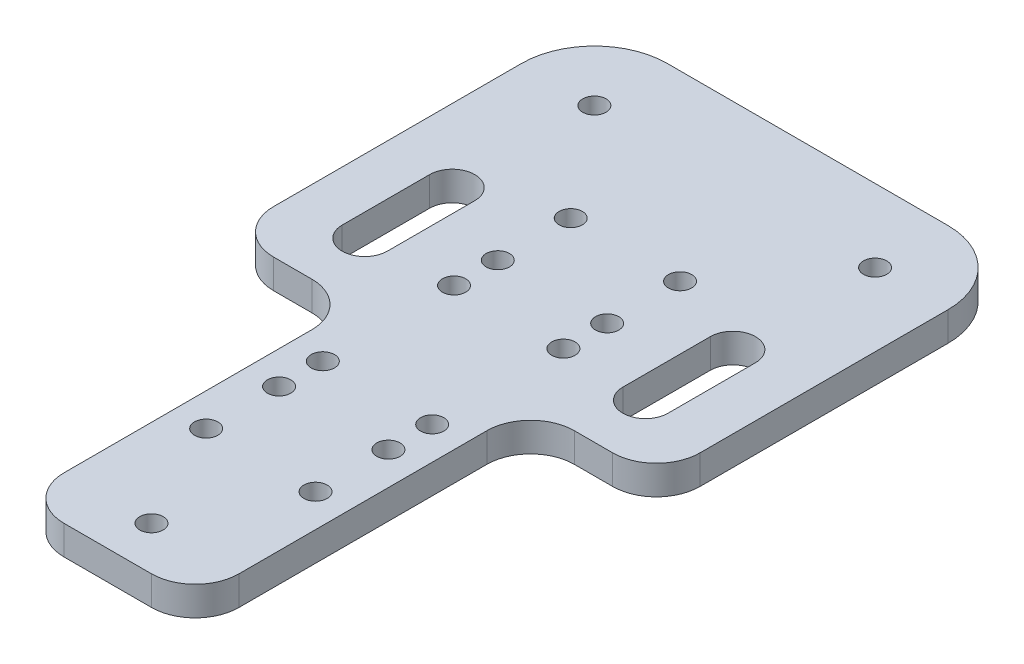
from build123d import *

# Parameters (mm, degrees)
SKETCH1_R           = 1.6
BOSS_EXTRUDE1_DEPTH = 4
FILLET1_R           = 6


with BuildPart() as part:
    # Sketch1 → Boss-Extrude1 (new body)
    with BuildSketch(Plane(origin=(0, 0, 0), x_dir=(1, 0, 0), z_dir=(0, 1, 0))):
        with BuildLine():
            Line((-29.25, 40), (-29.25, 0))
            Line((-29.25, 0), (-12, 0))
            Line((-12, 0), (-12, -46))
            Line((-12, -46), (12, -46))
            Line((12, -46), (12, 0))
            Line((12, 0), (29.25, 0))
            Line((29.25, 0), (29.25, 40))
            ThreePointArc((29.25, 40), (26.321067812, 47.071067812), (19.25, 50))
            Line((19.25, 50), (-19.25, 50))
            ThreePointArc((-19.25, 50), (-26.321067812, 47.071067812), (-29.25, 40))
        make_face()
        with Locations((-19.25, 40)):
            Circle(SKETCH1_R, mode=Mode.SUBTRACT)
        with Locations((19.25, 40)):
            Circle(SKETCH1_R, mode=Mode.SUBTRACT)
        with Locations((0, -40)):
            Circle(SKETCH1_R, mode=Mode.SUBTRACT)
        with Locations((-7.5, 25)):
            Circle(SKETCH1_R, mode=Mode.SUBTRACT)
        with Locations((7.5, 25)):
            Circle(SKETCH1_R, mode=Mode.SUBTRACT)
        with Locations((7.5, 15)):
            Circle(SKETCH1_R, mode=Mode.SUBTRACT)
        with Locations((-7.5, 15)):
            Circle(SKETCH1_R, mode=Mode.SUBTRACT)
        with Locations((-7.5, 9)):
            Circle(SKETCH1_R, mode=Mode.SUBTRACT)
        with Locations((7.5, 9)):
            Circle(SKETCH1_R, mode=Mode.SUBTRACT)
        with Locations((7.5, -9)):
            Circle(SKETCH1_R, mode=Mode.SUBTRACT)
        with Locations((-7.5, -9)):
            Circle(SKETCH1_R, mode=Mode.SUBTRACT)
        with Locations((7.5, -15)):
            Circle(SKETCH1_R, mode=Mode.SUBTRACT)
        with Locations((-7.5, -15)):
            Circle(SKETCH1_R, mode=Mode.SUBTRACT)
        with Locations((7.5, -25)):
            Circle(SKETCH1_R, mode=Mode.SUBTRACT)
        with Locations((-7.5, -25)):
            Circle(SKETCH1_R, mode=Mode.SUBTRACT)
        with BuildLine():
            Line((-16.15, 20.5), (-16.15, 8.5))
            ThreePointArc((-16.15, 8.5), (-19.25, 5.4), (-22.35, 8.5))
            Line((-22.35, 8.5), (-22.35, 20.5))
            ThreePointArc((-22.35, 20.5), (-19.25, 23.6), (-16.15, 20.5))
        make_face(mode=Mode.SUBTRACT)
        with BuildLine():
            Line((16.15, 20.5), (16.15, 8.5))
            ThreePointArc((16.15, 8.5), (19.25, 5.4), (22.35, 8.5))
            Line((22.35, 8.5), (22.35, 20.5))
            ThreePointArc((22.35, 20.5), (19.25, 23.6), (16.15, 20.5))
        make_face(mode=Mode.SUBTRACT)
    extrude(amount=BOSS_EXTRUDE1_DEPTH)

    # Fillet1
    fillet1_edges = [part.edges().sort_by_distance(p)[0] for p in [
        (29.25, 2, 0),
        (12, 2, 0),
        (12, 2, 46),
        (-12, 2, 46),
        (-12, 2, 0),
        (-29.25, 2, 0),
    ]]
    fillet(fillet1_edges, radius=FILLET1_R)


solid = part.part
